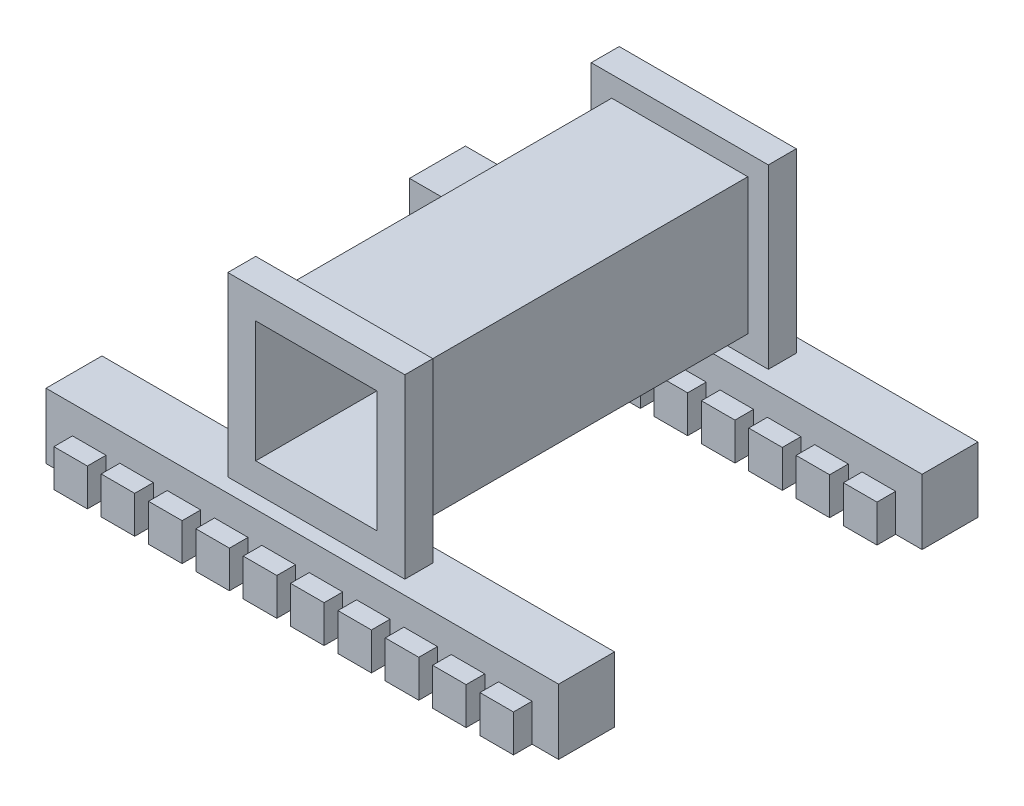
from build123d import *

# Parameters (mm, degrees)
EXTRUDE_1_DEPTH      = 21
SKETCH_1_3_W         = 13
SKETCH_1_3_H         = 13
CUT_EXTRUDE_1_DEPTH  = 21
SKETCH_1_12_W        = 19
SKETCH_1_12_H        = 19
SKETCH_1_12_W_2      = 14.6
SKETCH_1_12_H_2      = 14.6
SKETCH_1_12_W_3      = 13
SKETCH_1_12_H_3      = 13
CUT_EXTRUDE_6_DEPTH  = 18
CUT_EXTRUDE_7_DEPTH  = 14.5
SKETCH_4_W           = 3.504900739
SKETCH_4_H           = 7
SKETCH_4_W_2         = 3.5
EXTRUDE_2_DEPTH      = 27.5
CUT_EXTRUDE_9_DEPTH  = 2
SKETCH_7_W           = 3.6
SKETCH_7_H           = 3.966529086
CUT_EXTRUDE_10_DEPTH = 2
SKETCH_9_W           = 3.6
SKETCH_9_H           = 3.966529086
CUT_EXTRUDE_11_DEPTH = 2
SKETCH_10_W          = 3.6
SKETCH_10_H          = 3.966529086
CUT_EXTRUDE_12_DEPTH = 2


with BuildPart() as part:
    # 草图1 → 凸台-拉伸1 (new, symmetric)
    with BuildSketch(Plane.XY):
        Polygon((9.5, 9.5), (-9.5, 9.5), (-9.5, -9.5), (-27.5, -9.5), (-27.5, -16.5), (27.5, -16.5), (27.5, -9.5), (9.5, -9.5), align=None)
    extrude(amount=EXTRUDE_1_DEPTH, both=True)

    # 草图1<3> → 切除-拉伸1 (cut, symmetric)
    with BuildSketch(Plane.XY):
        Rectangle(SKETCH_1_3_W, SKETCH_1_3_H)
    extrude(amount=CUT_EXTRUDE_1_DEPTH, both=True, mode=Mode.SUBTRACT)

    # 草图1<12> → 切除-拉伸6 (cut, symmetric)
    # profile 1 of 2: a face of its own
    with BuildSketch(Plane.XY):
        Rectangle(SKETCH_1_12_W, SKETCH_1_12_H)
        Rectangle(SKETCH_1_12_W_2, SKETCH_1_12_H_2, mode=Mode.SUBTRACT)
    # profile 2 of 2: a face of its own
    with BuildSketch(Plane.XY):
        Rectangle(SKETCH_1_12_W_3, SKETCH_1_12_H_3)
    extrude(amount=CUT_EXTRUDE_6_DEPTH, both=True, mode=Mode.SUBTRACT)

    # 草图1<13> → 切除-拉伸7 (cut, symmetric)
    with BuildSketch(Plane.XY):
        Polygon((9.5, -9.5), (-9.5, -9.5), (-27.5, -9.5), (-27.5, -16.5), (27.5, -16.5), (27.5, -9.5), align=None)
    extrude(amount=CUT_EXTRUDE_7_DEPTH, both=True, mode=Mode.SUBTRACT)

    # 草图4 → 凸台-拉伸2 (add, symmetric)
    with BuildSketch(Plane(origin=(0, 0, 0), x_dir=(0, 0, -1), z_dir=(1, 0, 0))):
        with Locations((-22.752450369, -13)):
            Rectangle(SKETCH_4_W, SKETCH_4_H)
        with Locations((22.75, -13)):
            Rectangle(SKETCH_4_W_2, SKETCH_4_H)
    extrude(amount=EXTRUDE_2_DEPTH, both=True)

    # 草图5 → 切除-拉伸9 (cut)
    with BuildSketch(Plane(origin=(0, 0, -24.5), x_dir=(-1, 0, 0), z_dir=(0, 0, -1))):
        Polygon((-27.5, -9.5), (-27.5, -16.5), (-24.66, -16.5), (-24.66, -12.503647236), (-22.86, -12.503647236), (-21.06, -12.503647236), (-21.06, -16.5), (-19.58, -16.5), (-19.58, -12.503647236), (-17.78, -12.503647236), (-15.98, -12.503647236), (-15.98, -16.5), (-14.5, -16.5), (-14.5, -12.503647236), (-12.7, -12.503647236), (-10.9, -12.503647236), (-10.9, -16.5), (-9.42, -16.5), (-9.42, -12.503647236), (-7.62, -12.503647236), (-5.82, -12.503647236), (-5.82, -16.5), (-4.34, -16.5), (-4.34, -12.511103156), (-0.74, -12.511103156), (-0.74, -16.5), (0.731971317, -16.5), (0.731971317, -12.518559075), (2.535985659, -12.518559075), (4.34, -12.518559075), (4.34, -16.5), (7.62, -16.5), (10.896293739, -16.5), (10.896293739, -12.507758798), (12.698146869, -12.507758798), (14.5, -12.507758798), (14.5, -16.5), (15.980045705, -16.5), (15.980045705, -12.508203705), (17.780055728, -12.508203705), (19.580065752, -12.508203705), (19.580065752, -16.5), (21.06, -16.5), (21.06, -12.508203705), (22.859139551, -12.508203705), (24.658279102, -12.508203705), (24.658279102, -16.5), (27.5, -16.5), (27.5, -9.5), (9.5, -9.5), (-9.5, -9.5), align=None)
        Polygon((9.42, -16.487143942), (7.62, -16.487143942), (5.82, -16.487143942), (5.82, -12.520614856), (7.62, -12.520614856), (9.42, -12.520614856), align=None, mode=Mode.SUBTRACT)
    extrude(amount=-CUT_EXTRUDE_9_DEPTH, mode=Mode.SUBTRACT)

    # 草图7 → 切除-拉伸10 (cut)
    with BuildSketch(Plane(origin=(0, 0, 14.5), x_dir=(-1, 0, 0), z_dir=(0, 0, -1))):
        Polygon((19.580065752, -16.5), (21.06, -16.5), (21.06, -12.508203705), (24.658279102, -12.508203705), (24.658279102, -16.5), (27.5, -16.5), (27.5, -9.5), (-27.5, -9.5), (-27.5, -16.5), (-24.66, -16.5), (-24.66, -12.503647236), (-21.06, -12.503647236), (-21.06, -16.5), (-19.58, -16.5), (-19.58, -12.503647236), (-15.98, -12.503647236), (-15.98, -16.5), (-14.5, -16.5), (-14.5, -12.503647236), (-10.9, -12.503647236), (-10.9, -16.5), (-9.42, -16.5), (-9.42, -12.503647236), (-5.82, -12.503647236), (-5.82, -16.5), (-4.34, -16.5), (-4.34, -12.511103156), (-0.74, -12.511103156), (-0.74, -16.5), (0.731971317, -16.5), (0.731971317, -12.518559075), (4.34, -12.518559075), (4.34, -16.5), (10.896293739, -16.5), (10.896293739, -12.507758798), (14.5, -12.507758798), (14.5, -16.5), (15.980045705, -16.5), (15.980045705, -12.508203705), (19.580065752, -12.508203705), align=None)
        with Locations((7.62, -14.503879399)):
            Rectangle(SKETCH_7_W, SKETCH_7_H, mode=Mode.SUBTRACT)
    extrude(amount=-CUT_EXTRUDE_10_DEPTH, mode=Mode.SUBTRACT)

    # 草图9 → 切除-拉伸11 (cut)
    with BuildSketch(Plane.XY.offset(-14.5)):
        Polygon((24.66, -16.5), (27.5, -16.5), (27.5, -9.5), (-27.5, -9.5), (-27.5, -16.5), (-24.658279102, -16.5), (-24.658279102, -12.508203705), (-21.06, -12.508203705), (-21.06, -16.5), (-19.580065752, -16.5), (-19.580065752, -12.508203705), (-15.980045705, -12.508203705), (-15.980045705, -16.5), (-14.5, -16.5), (-14.5, -12.507758798), (-10.896293739, -12.507758798), (-10.896293739, -16.5), (-4.34, -16.5), (-4.34, -12.518559075), (-0.731971317, -12.518559075), (-0.731971317, -16.5), (0.74, -16.5), (0.74, -12.511103156), (4.34, -12.511103156), (4.34, -16.5), (5.82, -16.5), (5.82, -12.503647236), (9.42, -12.503647236), (9.42, -16.5), (10.9, -16.5), (10.9, -12.503647236), (14.5, -12.503647236), (14.5, -16.5), (15.98, -16.5), (15.98, -12.503647236), (19.58, -12.503647236), (19.58, -16.5), (21.06, -16.5), (21.06, -12.503647236), (24.66, -12.503647236), align=None)
        with Locations((-7.62, -14.503879399)):
            Rectangle(SKETCH_9_W, SKETCH_9_H, mode=Mode.SUBTRACT)
    extrude(amount=-CUT_EXTRUDE_11_DEPTH, mode=Mode.SUBTRACT)

    # 草图10 → 切除-拉伸12 (cut)
    with BuildSketch(Plane.XY.offset(24.504900739)):
        Polygon((27.5, -9.5), (-27.5, -9.5), (-27.5, -16.5), (-24.658279102, -16.5), (-24.658279102, -12.508203705), (-21.06, -12.508203705), (-21.06, -16.5), (-19.580065752, -16.5), (-19.580065752, -12.508203705), (-15.980045705, -12.508203705), (-15.980045705, -16.5), (-14.5, -16.5), (-14.5, -12.507758798), (-10.896293739, -12.507758798), (-10.896293739, -16.5), (-4.34, -16.5), (-4.34, -12.518559075), (-0.731971317, -12.518559075), (-0.731971317, -16.5), (0.74, -16.5), (0.74, -12.511103156), (4.34, -12.511103156), (4.34, -16.5), (5.82, -16.5), (5.82, -12.503647236), (9.42, -12.503647236), (9.42, -16.5), (10.9, -16.5), (10.9, -12.503647236), (14.5, -12.503647236), (14.5, -16.5), (15.98, -16.5), (15.98, -12.503647236), (19.58, -12.503647236), (19.58, -16.5), (21.06, -16.5), (21.06, -12.503647236), (24.66, -12.503647236), (24.66, -16.5), (27.5, -16.5), align=None)
        with Locations((-7.62, -14.503879399)):
            Rectangle(SKETCH_10_W, SKETCH_10_H, mode=Mode.SUBTRACT)
    extrude(amount=-CUT_EXTRUDE_12_DEPTH, mode=Mode.SUBTRACT)


solid = part.part
